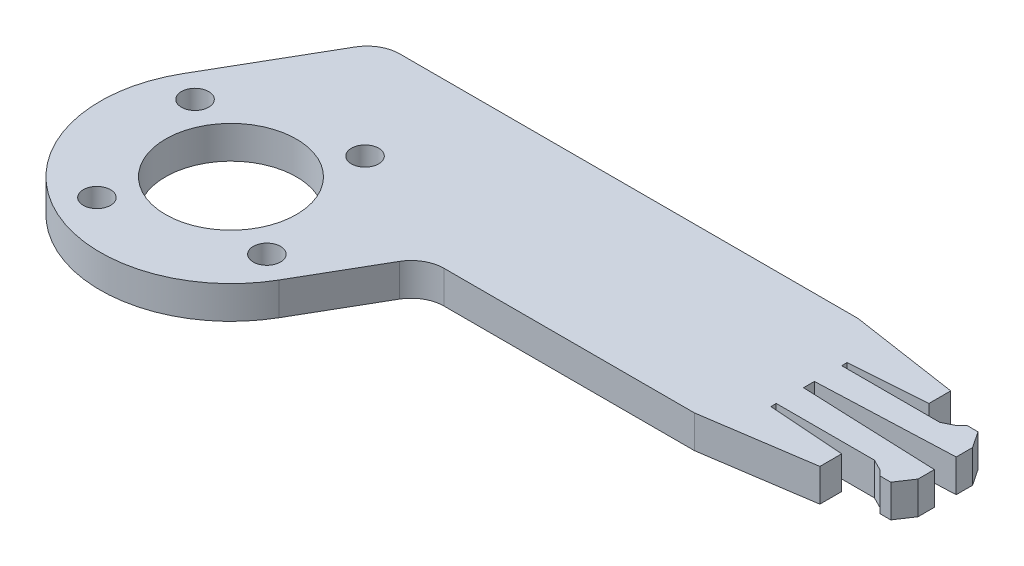
from build123d import *

# Parameters (mm, degrees)
SKETCH1_R           = 1.25
SKETCH1_R_2         = 6
BOSS_EXTRUDE1_DEPTH = 1.5
FILLET1_R           = 3


with BuildPart() as part:
    # Sketch1 → Boss-Extrude1 (new body, symmetric)
    with BuildSketch(Plane(origin=(0, 0, 0), x_dir=(1, 0, 0), z_dir=(0, 1, 0))):
        with BuildLine():
            Line((50, 4), (40, 2.5))
            Line((40, 2.5), (15.299782134, 2.5))
            Line((15.299782134, 2.5), (10.392304845, -6))
            ThreePointArc((10.392304845, -6), (-6, -10.392304845), (-10.392304845, 6))
            Line((-10.392304845, 6), (-3.75277675, 17.5))
            Line((-3.75277675, 17.5), (40, 17.5))
            Line((40, 17.5), (50, 16))
            Line((50, 16), (50, 14))
            Line((50, 14), (43, 13.5))
            Line((43, 13.5), (43, 13))
            Line((43, 13), (52, 13))
            Line((52, 13), (53, 13.5))
            Line((53, 13.5), (53.5, 14))
            Line((53.5, 14), (54.5, 14))
            Line((54.5, 14), (55.5, 12.5))
            Line((55.5, 12.5), (55.5, 11))
            Line((55.5, 11), (43, 10.5))
            Line((43, 10.5), (43, 9.5))
            Line((43, 9.5), (55.5, 9))
            Line((55.5, 9), (55.5, 7.5))
            Line((55.5, 7.5), (54.5, 6))
            Line((54.5, 6), (53.5, 6))
            Line((53.5, 6), (53, 6.5))
            Line((53, 6.5), (52, 7))
            Line((52, 7), (43, 7))
            Line((43, 7), (43, 6.5))
            Line((43, 6.5), (50, 6))
            Line((50, 6), (50, 4))
        make_face()
        with Locations((7.794228634, -4.5)):
            Circle(SKETCH1_R, mode=Mode.SUBTRACT)
        with Locations((-4.5, -7.794228634)):
            Circle(SKETCH1_R, mode=Mode.SUBTRACT)
        with Locations((-7.794228634, 4.5)):
            Circle(SKETCH1_R, mode=Mode.SUBTRACT)
        with Locations((4.5, 7.794228634)):
            Circle(SKETCH1_R, mode=Mode.SUBTRACT)
        Circle(SKETCH1_R_2, mode=Mode.SUBTRACT)
    extrude(amount=BOSS_EXTRUDE1_DEPTH, both=True)

    # Fillet1
    fillet1_edges = [part.edges().sort_by_distance(p)[0] for p in [
        (15.299782134, 0, -2.5),
        (-3.75277675, 0, -17.5),
    ]]
    fillet(fillet1_edges, radius=FILLET1_R)


solid = part.part
